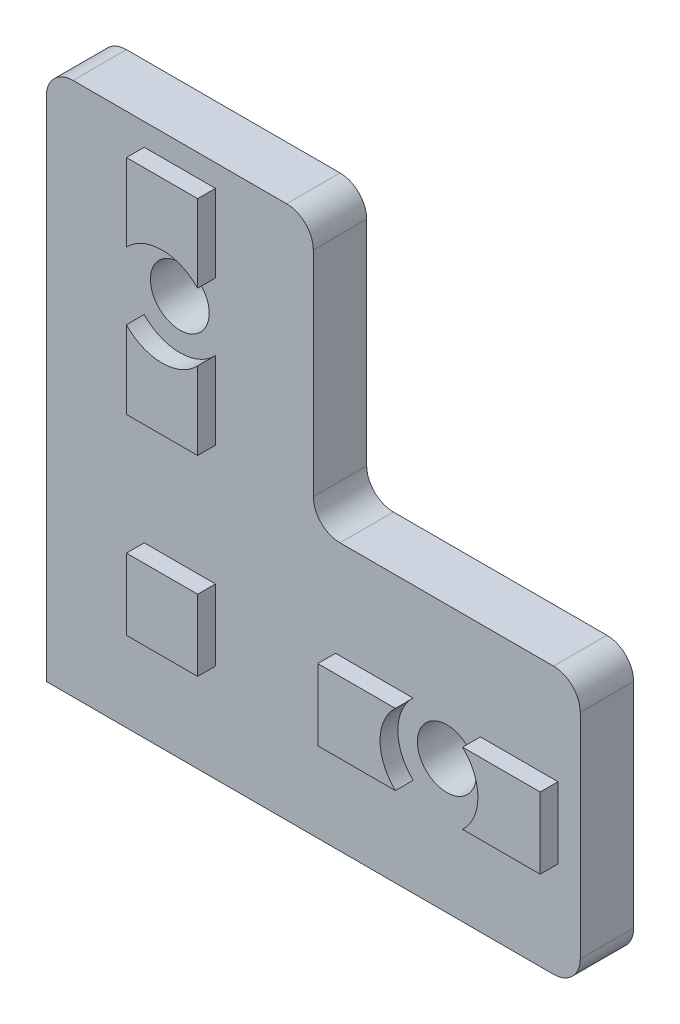
from build123d import *

# Parameters (mm, degrees)
P_IDAT_VYSUNUT_M1_DEPTH = 6
M6_D_RA_S_V_L_1_D       = 6.6
SKICA5_W                = 8
SKICA5_H                = 8
P_IDAT_VYSUNUT_M2_DEPTH = 2


with BuildPart() as part:
    # Skica1 → Přidat vysunutím1 (new body)
    with BuildSketch(Plane.XY):
        with BuildLine():
            Line((0, 0), (57, 0))
            ThreePointArc((57, 0), (59.121320344, 0.878679656), (60, 3))
            Line((60, 3), (60, 27))
            ThreePointArc((60, 27), (59.121320344, 29.121320344), (57, 30))
            Line((57, 30), (33, 30))
            ThreePointArc((33, 30), (30.878679656, 30.878679656), (30, 33))
            Line((30, 33), (30, 57))
            ThreePointArc((30, 57), (29.121320344, 59.121320344), (27, 60))
            Line((27, 60), (3, 60))
            ThreePointArc((3, 60), (0.878679656, 59.121320344), (0, 57))
            Line((0, 57), (0, 0))
        make_face()
    extrude(amount=P_IDAT_VYSUNUT_M1_DEPTH)

    # M6 díra s vůlí1 (through all)
    with Locations(Plane.XY.offset(6)):
        with Locations((45, 15), (15, 45)):
            Hole(M6_D_RA_S_V_L_1_D / 2)

    # Skica5 → Přidat vysunutím2 (add)
    with BuildSketch(Plane.XY.offset(6)):
        with BuildLine():
            ThreePointArc((19, 41.225082782), (15, 39.5), (11, 41.225082782))
            Line((11, 41.225082782), (11, 32.5))
            Line((11, 32.5), (19, 32.5))
            Line((19, 32.5), (19, 41.225082782))
        make_face()
        with BuildLine():
            Line((19, 57.5), (11, 57.5))
            Line((11, 57.5), (11, 48.774917218))
            ThreePointArc((11, 48.774917218), (15, 50.5), (19, 48.774917218))
            Line((19, 48.774917218), (19, 57.5))
        make_face()
        with BuildLine():
            Line((41.225082782, 19), (32.5, 19))
            Line((32.5, 19), (32.5, 11))
            Line((32.5, 11), (41.225082782, 11))
            ThreePointArc((41.225082782, 11), (39.5, 15), (41.225082782, 19))
        make_face()
        with BuildLine():
            Line((57.5, 19), (48.774917218, 19))
            ThreePointArc((48.774917218, 19), (50.050348735, 17.178067412), (50.5, 15))
            ThreePointArc((50.5, 15), (50.050348735, 12.821932588), (48.774917218, 11))
            Line((48.774917218, 11), (57.5, 11))
            Line((57.5, 11), (57.5, 19))
        make_face()
        with Locations((15, 15)):
            Rectangle(SKICA5_W, SKICA5_H)
    extrude(amount=P_IDAT_VYSUNUT_M2_DEPTH)


solid = part.part
